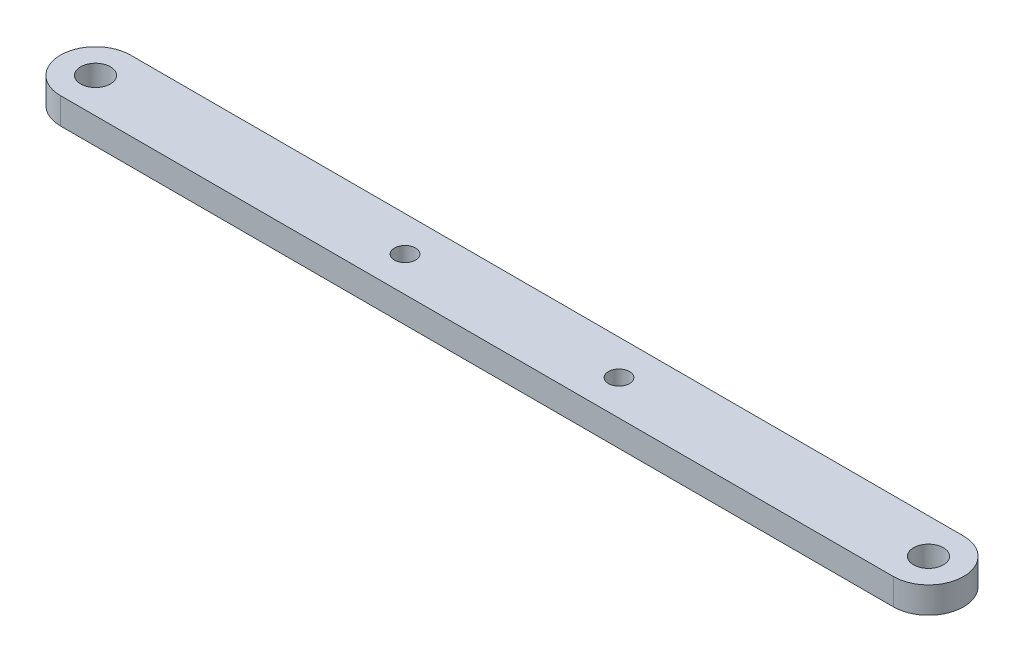
from build123d import *

# Parameters (mm, degrees)
BOSS_EXTRUDE1_DEPTH  = 3
M3_CLEARANCE_HOLE1_D = 3.4
M2_CLEARANCE_HOLE1_D = 2.4


with BuildPart() as part:
    # Sketch1 → Boss-Extrude1 (new body)
    with BuildSketch(Plane(origin=(0, 0, 0), x_dir=(1, 0, 0), z_dir=(0, 1, 0))):
        with BuildLine():
            Line((0, 4), (95, 4))
            ThreePointArc((95, 4), (99, 0), (95, -4))
            Line((95, -4), (0, -4))
            ThreePointArc((0, -4), (-4, 0), (0, 4))
        make_face()
    extrude(amount=BOSS_EXTRUDE1_DEPTH)

    # M3 Clearance Hole1 (through all)
    with Locations(Plane(origin=(0, 3, 0), x_dir=(1, 0, 0), z_dir=(0, 1, 0))):
        with Locations((95, 0), (0, 0)):
            Hole(M3_CLEARANCE_HOLE1_D / 2)

    # M2 Clearance Hole1 (through all)
    with Locations(Plane(origin=(0, 3, 0), x_dir=(1, 0, 0), z_dir=(0, 1, 0))):
        with Locations((59.7, 0), (35.3, 0)):
            Hole(M2_CLEARANCE_HOLE1_D / 2)


solid = part.part
